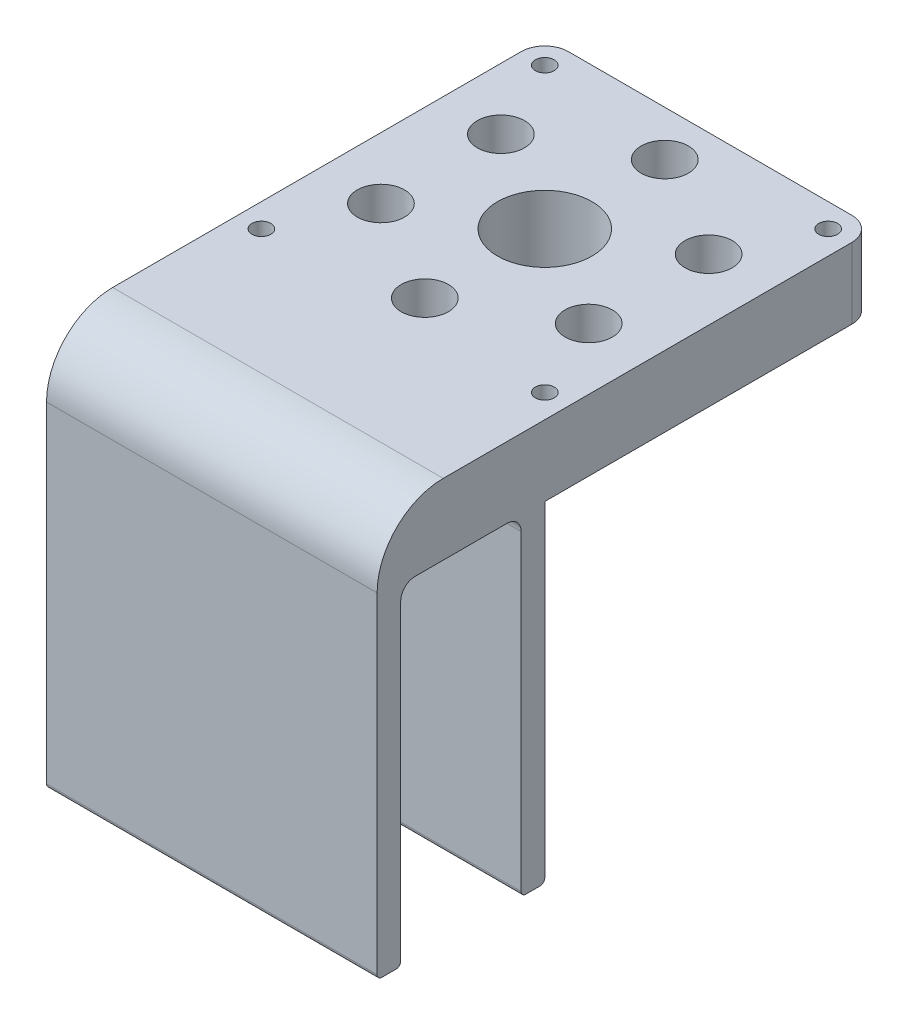
from build123d import *

# Parameters (mm, degrees)
SKETCH1_W           = 70
SKETCH1_H           = 70
SKETCH1_R           = 2.6
SKETCH1_R_2         = 10
SKETCH1_R_3         = 2
BOSS_EXTRUDE1_DEPTH = 15
SKETCH2_R           = 5
SKETCH2_R_2         = 2.6
CUT_EXTRUDE1_DEPTH  = 11
BOSS_EXTRUDE2_DEPTH = 70
FILLET1_R           = 5
FILLET2_R           = 1


with BuildPart() as part:
    # Sketch1 → Boss-Extrude1 (new body)
    with BuildSketch(Plane(origin=(0, 0, 0), x_dir=(1, 0, 0), z_dir=(0, 1, 0))):
        Rectangle(SKETCH1_W, SKETCH1_H)
        with Locations((0, 25.4)):
            Circle(SKETCH1_R, mode=Mode.SUBTRACT)
        with Locations((21.997045256, 12.7)):
            Circle(SKETCH1_R, mode=Mode.SUBTRACT)
        with Locations((21.997045256, -12.7)):
            Circle(SKETCH1_R, mode=Mode.SUBTRACT)
        with Locations((0, -25.4)):
            Circle(SKETCH1_R, mode=Mode.SUBTRACT)
        with Locations((-21.997045256, -12.7)):
            Circle(SKETCH1_R, mode=Mode.SUBTRACT)
        with Locations((-21.997045256, 12.7)):
            Circle(SKETCH1_R, mode=Mode.SUBTRACT)
        Circle(SKETCH1_R_2, mode=Mode.SUBTRACT)
        with Locations((-30, 30)):
            Circle(SKETCH1_R_3, mode=Mode.SUBTRACT)
        with Locations((30, 30)):
            Circle(SKETCH1_R_3, mode=Mode.SUBTRACT)
        with Locations((30, -30)):
            Circle(SKETCH1_R_3, mode=Mode.SUBTRACT)
        with Locations((-30, -30)):
            Circle(SKETCH1_R_3, mode=Mode.SUBTRACT)
    extrude(amount=BOSS_EXTRUDE1_DEPTH)

    # Sketch2 → Cut-Extrude1 (cut)
    with BuildSketch(Plane(origin=(0, 15, 0), x_dir=(1, 0, 0), z_dir=(0, 1, 0))):
        with Locations((-21.997045256, -12.7)):
            Circle(SKETCH2_R)
        with Locations((-21.997045256, -12.7)):
            Circle(SKETCH2_R_2, mode=Mode.SUBTRACT)
        with Locations((0, -25.4)):
            Circle(SKETCH2_R)
        with Locations((0, -25.4)):
            Circle(SKETCH2_R_2, mode=Mode.SUBTRACT)
        with Locations((21.997045256, -12.7)):
            Circle(SKETCH2_R)
        with Locations((21.997045256, -12.7)):
            Circle(SKETCH2_R_2, mode=Mode.SUBTRACT)
        with Locations((21.997045256, 12.7)):
            Circle(SKETCH2_R)
        with Locations((21.997045256, 12.7)):
            Circle(SKETCH2_R_2, mode=Mode.SUBTRACT)
        with Locations((0, 25.4)):
            Circle(SKETCH2_R)
        with Locations((0, 25.4)):
            Circle(SKETCH2_R_2, mode=Mode.SUBTRACT)
        with Locations((-21.997045256, 12.7)):
            Circle(SKETCH2_R)
        with Locations((-21.997045256, 12.7)):
            Circle(SKETCH2_R_2, mode=Mode.SUBTRACT)
    extrude(amount=-CUT_EXTRUDE1_DEPTH, mode=Mode.SUBTRACT)

    # Sketch3 → Boss-Extrude2 (add)
    with BuildSketch(Plane.ZY.offset(35)):
        with BuildLine():
            Line((35, 0), (35, -70))
            Line((35, -70), (40, -70))
            Line((40, -70), (40, -3))
            ThreePointArc((40, -3), (40.878679656, -0.878679656), (43, 0))
            Line((43, 0), (62.5, 0))
            ThreePointArc((62.5, 0), (64.621320344, -0.878679656), (65.5, -3))
            Line((65.5, -3), (65.5, -70))
            Line((65.5, -70), (70.5, -70))
            Line((70.5, -70), (70.5, 0))
            Line((70.5, 0), (70.5, 1))
            ThreePointArc((70.5, 1), (66.399494937, 10.899494937), (56.5, 15))
            Line((56.5, 15), (35, 15))
            Line((35, 15), (35, 0))
        make_face()
    extrude(amount=-BOSS_EXTRUDE2_DEPTH)

    # Fillet1
    fillet1_edges = [part.edges().sort_by_distance(p)[0] for p in [
        (-35, 7.5, -35),
        (35, 7.5, -35),
    ]]
    fillet(fillet1_edges, radius=FILLET1_R)

    # Fillet2
    fillet2_edges = [part.edges().sort_by_distance(p)[0] for p in [
        (0, -70, 70.5),
        (0, -70, 65.5),
        (0, -70, 40),
        (0, -70, 35),
    ]]
    fillet(fillet2_edges, radius=FILLET2_R)


solid = part.part
